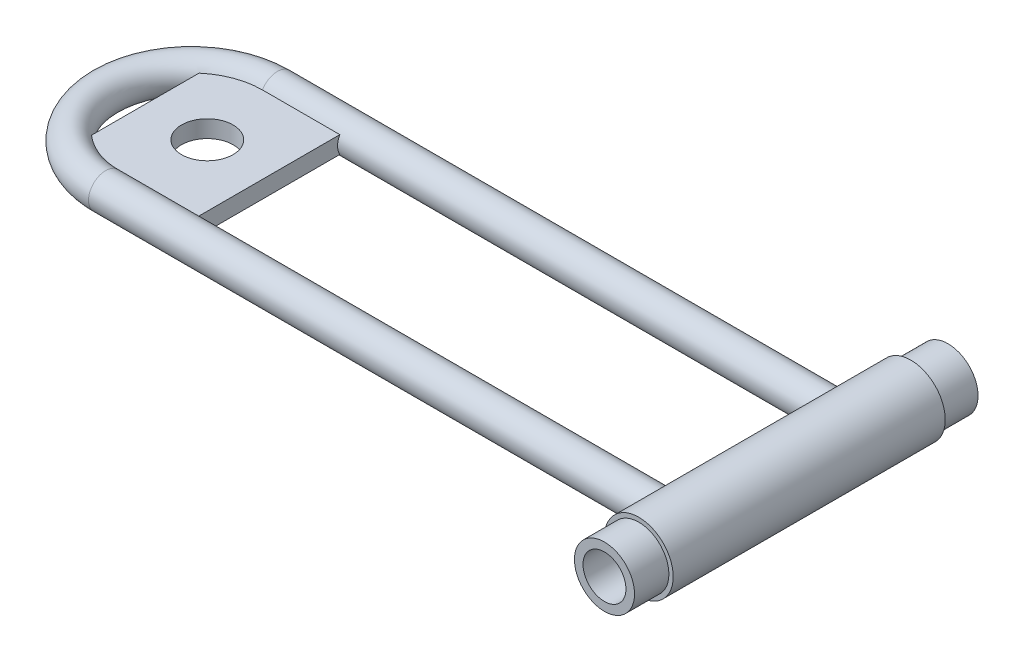
from build123d import *

# Parameters (mm, degrees)
SKETCH1_R           = 6.35
SKETCH1_R_2         = 3.175
BOSS_EXTRUDE1_DEPTH = 62.992
SKETCH3_R           = 3.175
SKETCH6_W           = 22.86
SKETCH6_H           = 1.5875
BOSS_EXTRUDE3_DEPTH = 29.21
SKETCH7_R           = 4.7625
CUT_EXTRUDE1_DEPTH  = 29.21
SKETCH9_R           = 6.35
SKETCH9_R_2         = 3.175
BOSS_EXTRUDE5_DEPTH = 6.35
SKETCH10_R          = 6.35
SKETCH10_R_2        = 5.55625
CUT_EXTRUDE6_DEPTH  = 12.7
SKETCH12_R          = 6.35
SKETCH12_R_2        = 5.55625
CUT_EXTRUDE7_DEPTH  = 12.7
SKETCH13_R          = 5.55625
SKETCH13_R_2        = 3.175
CUT_EXTRUDE8_DEPTH  = 6.35
SKETCH14_R          = 5.55625
SKETCH14_R_2        = 3.175
CUT_EXTRUDE9_DEPTH  = 6.35
SKETCH16_R          = 3.96875
CUT_EXTRUDE11_DEPTH = 142.896915114
SKETCH18_R          = 5.55625
SKETCH18_R_2        = 3.96875
BOSS_EXTRUDE7_DEPTH = 0.508


with BuildPart() as part:
    # Sketch1 → Boss-Extrude1 (new body)
    with BuildSketch(Plane.XY):
        Circle(SKETCH1_R)
        Circle(SKETCH1_R_2, mode=Mode.SUBTRACT)
    extrude(amount=BOSS_EXTRUDE1_DEPTH)

    # Sweep1: sweep along a path in Sketch4
    with BuildLine(Plane(origin=(0, 0, 0), x_dir=(1, 0, 0), z_dir=(0, 1, 0))) as sweep1_path:
        Line((-3.81, -15.663931971), (-107.95, -15.663931971))
        ThreePointArc((-107.95, -15.663931971), (-123.665226198, -31.37915817), (-107.95, -47.094384368))
        Line((-107.95, -47.094384368), (-3.81, -47.094384368))
    # Sketch3 → Sweep1 (sweep)
    with BuildSketch(Plane.ZY.offset(3.81)):
        with Locations((47.244, 0)):
            Circle(SKETCH3_R)
    sweep(path=sweep1_path.line)

    # Sketch6 → Boss-Extrude3 (add)
    with BuildSketch(Plane.XY.offset(15.24)):
        with Locations((-105.071320577, -0.79375)):
            Rectangle(SKETCH6_W, SKETCH6_H)
        with Locations((-105.071320577, 0.79375)):
            Rectangle(SKETCH6_W, SKETCH6_H)
    extrude(amount=BOSS_EXTRUDE3_DEPTH)

    # Sketch7 → Cut-Extrude1 (cut)
    with BuildSketch(Plane(origin=(0, 1.5875, 0), x_dir=(1, 0, 0), z_dir=(0, 1, 0))):
        with Locations(Location((-105.071320577, -31.341130791, 0), (0, 0, 180))):
            Circle(SKETCH7_R)
    extrude(amount=-CUT_EXTRUDE1_DEPTH, mode=Mode.SUBTRACT)

    # Sketch9 → Boss-Extrude5 (add)
    with BuildSketch(Plane(origin=(0, 0, 0), x_dir=(-1, 0, 0), z_dir=(0, 0, -1))):
        Circle(SKETCH9_R)
        Circle(SKETCH9_R_2, mode=Mode.SUBTRACT)
    boss_extrude5 = extrude(amount=BOSS_EXTRUDE5_DEPTH)

    # Mirror1: Boss-Extrude5 across plane
    add(boss_extrude5.mirror(Plane.XY.offset(31.496)))

    # Sketch10 → Cut-Extrude6 (cut)
    with BuildSketch(Plane.XY.offset(69.342)):
        with Locations(Location((0, 0, 0), (0, 0, 180))):
            Circle(SKETCH10_R)
        with Locations(Location((0, 0, 0), (0, 0, 180))):
            Circle(SKETCH10_R_2, mode=Mode.SUBTRACT)
    extrude(amount=-CUT_EXTRUDE6_DEPTH, mode=Mode.SUBTRACT)

    # Sketch12 → Cut-Extrude7 (cut)
    with BuildSketch(Plane(origin=(0, 0, -6.35), x_dir=(-1, 0, 0), z_dir=(0, 0, -1))):
        Circle(SKETCH12_R)
        Circle(SKETCH12_R_2, mode=Mode.SUBTRACT)
    extrude(amount=-CUT_EXTRUDE7_DEPTH, mode=Mode.SUBTRACT)

    # Sketch13 → Cut-Extrude8 (cut)
    with BuildSketch(Plane.XY.offset(69.342)):
        with Locations(Location((0, 0, 0), (0, 0, 180))):
            Circle(SKETCH13_R)
        Circle(SKETCH13_R_2, mode=Mode.SUBTRACT)
    extrude(amount=-CUT_EXTRUDE8_DEPTH, mode=Mode.SUBTRACT)

    # Sketch14 → Cut-Extrude9 (cut)
    with BuildSketch(Plane(origin=(0, 0, -6.35), x_dir=(-1, 0, 0), z_dir=(0, 0, -1))):
        Circle(SKETCH14_R)
        Circle(SKETCH14_R_2, mode=Mode.SUBTRACT)
    extrude(amount=-CUT_EXTRUDE9_DEPTH, mode=Mode.SUBTRACT)

    # Sketch16 → Cut-Extrude11 (cut, through all)
    with BuildSketch(Plane(origin=(0, 0, 0), x_dir=(-1, 0, 0), z_dir=(0, 0, -1))):
        Circle(SKETCH16_R)
    extrude(amount=-CUT_EXTRUDE11_DEPTH, mode=Mode.SUBTRACT)

    # Sketch18 → Boss-Extrude7 (add)
    with BuildSketch(Plane(origin=(0, 0, 0), x_dir=(-1, 0, 0), z_dir=(0, 0, -1))):
        Circle(SKETCH18_R)
        Circle(SKETCH18_R_2, mode=Mode.SUBTRACT)
    extrude(amount=BOSS_EXTRUDE7_DEPTH)


solid = part.part
